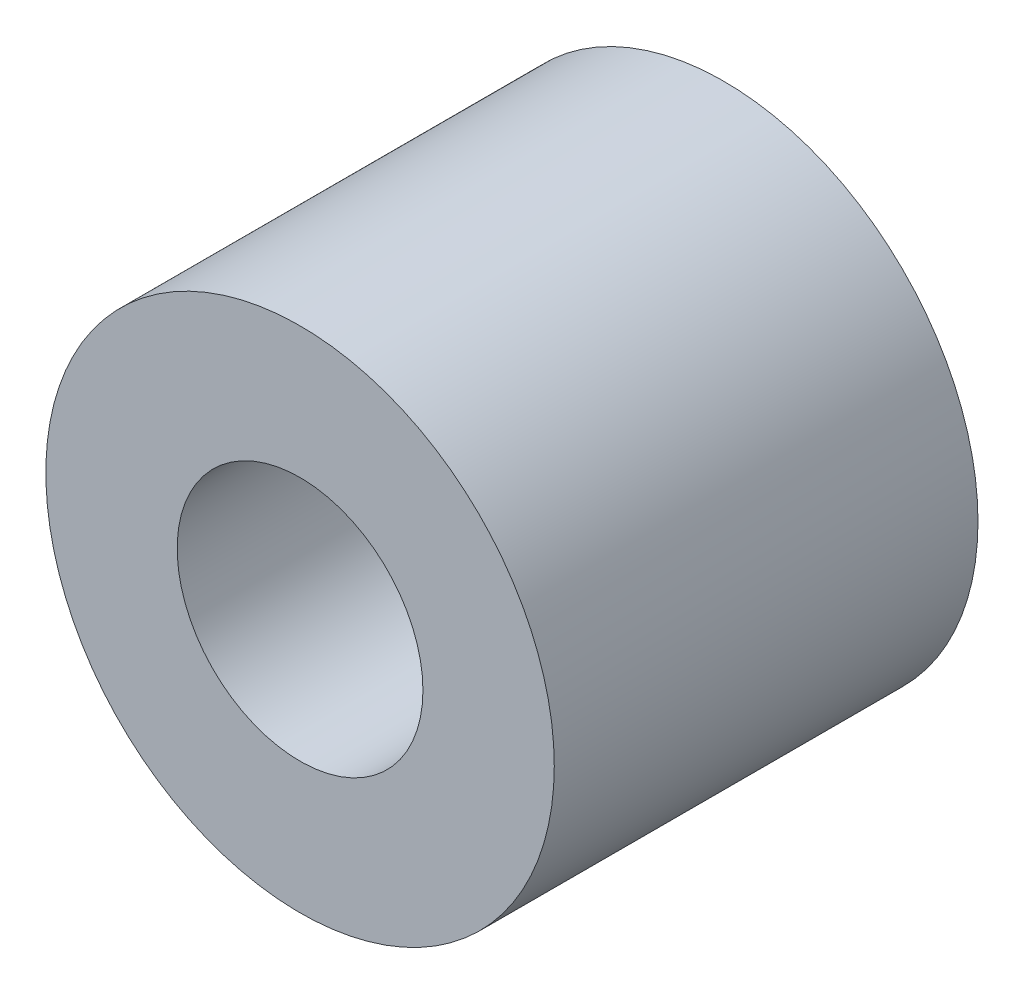
from build123d import *

# Parameters (mm, degrees)
SKETCH_1_R      = 3
SKETCH_1_R_2    = 1.45
EXTRUDE_1_DEPTH = 5


with BuildPart() as part:
    # Эскиз1 → Бобышка-Вытянуть1 (new body)
    with BuildSketch(Plane.XY):
        Circle(SKETCH_1_R)
        Circle(SKETCH_1_R_2, mode=Mode.SUBTRACT)
    extrude(amount=EXTRUDE_1_DEPTH)


solid = part.part
